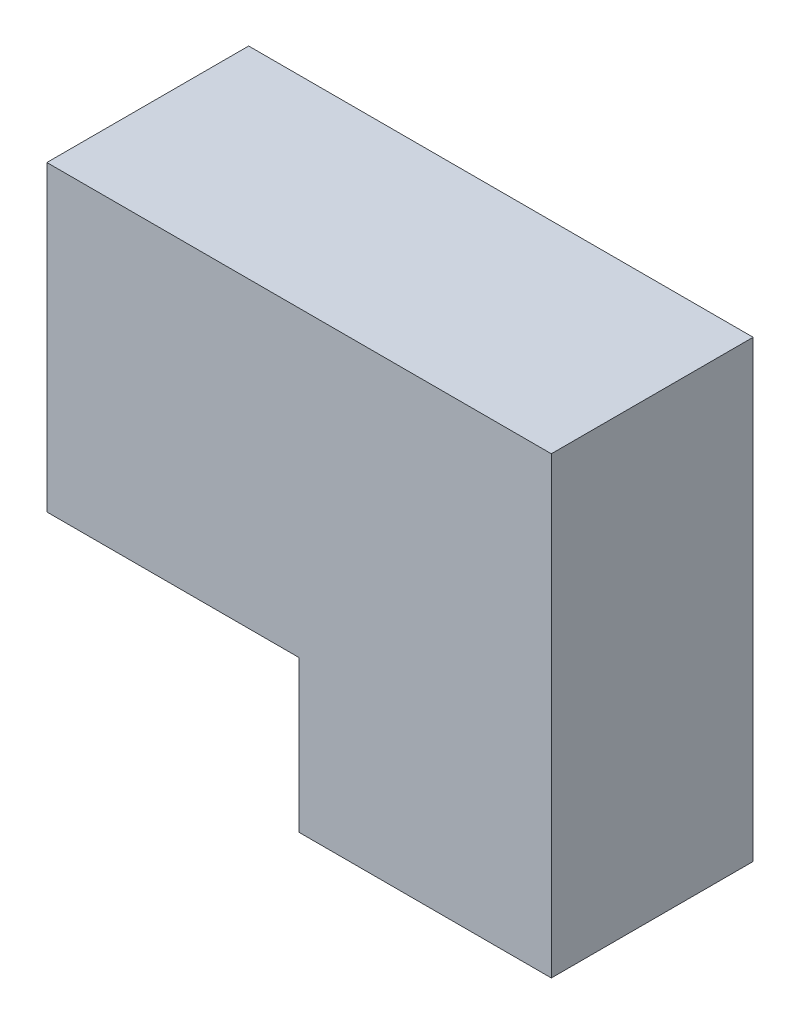
from build123d import *

# Parameters (mm, degrees)
BOSS_EXTRUDE1_DEPTH = 4


with BuildPart() as part:
    # Sketch1 → Boss-Extrude1 (new body)
    with BuildSketch(Plane.XY):
        Polygon((0, 0), (0, 3), (-5, 3), (-5, 9), (5, 9), (5, 0), align=None)
    extrude(amount=BOSS_EXTRUDE1_DEPTH)


solid = part.part
